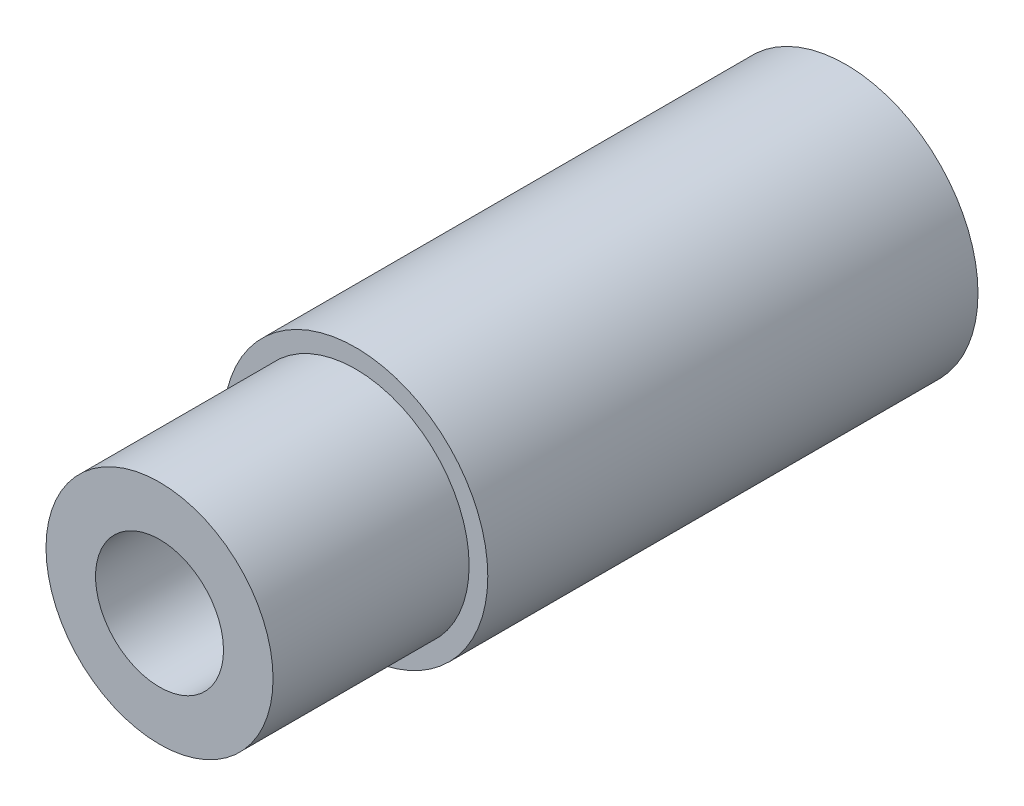
from build123d import *

# Parameters (mm, degrees)
SKETCH1_R           = 3.25374
SKETCH1_R_2         = 1.5748
BOSS_EXTRUDE1_DEPTH = 12.065
SKETCH2_R           = 2.794
SKETCH2_R_2         = 1.5748
BOSS_EXTRUDE2_DEPTH = 4.826


with BuildPart() as part:
    # Sketch1 → Boss-Extrude1 (new body)
    with BuildSketch(Plane.XY):
        Circle(SKETCH1_R)
        Circle(SKETCH1_R_2, mode=Mode.SUBTRACT)
    extrude(amount=BOSS_EXTRUDE1_DEPTH)

    # Sketch2 → Boss-Extrude2 (add)
    with BuildSketch(Plane.XY.offset(12.065)):
        Circle(SKETCH2_R)
        Circle(SKETCH2_R_2, mode=Mode.SUBTRACT)
    extrude(amount=BOSS_EXTRUDE2_DEPTH)


solid = part.part
